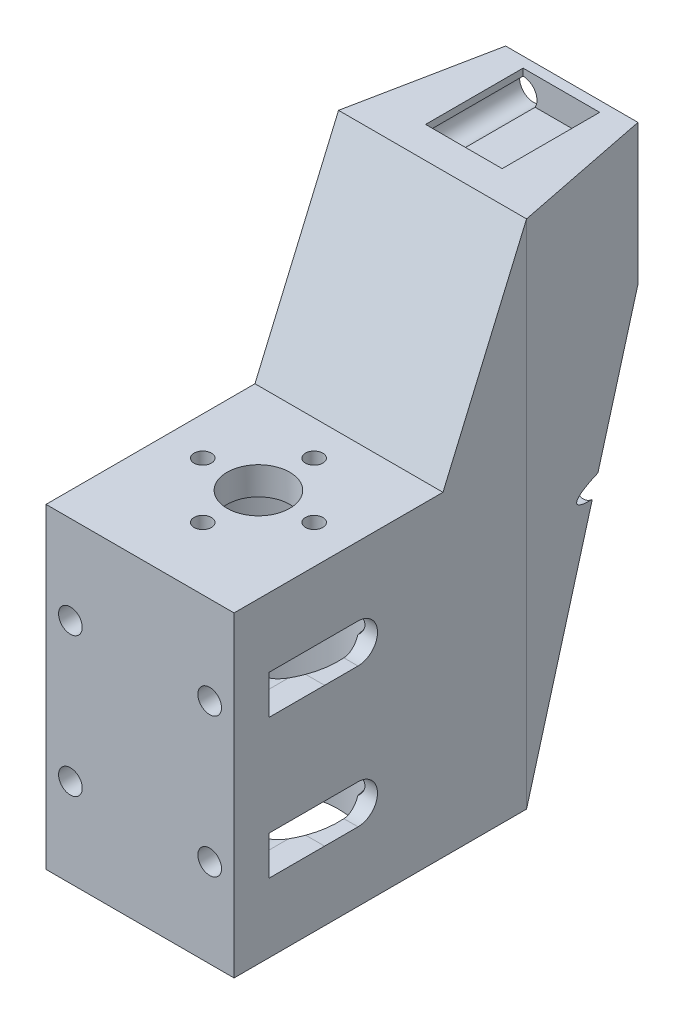
from build123d import *

# Parameters (mm, degrees)
SKETCH1_W                                       = 27
SKETCH1_H                                       = 62
BOSS_EXTRUDE1_DEPTH                             = 73.4
SKETCH2_R                                       = 2
CUT_EXTRUDE1_DEPTH                              = 20
SKETCH4_W                                       = 11
SKETCH4_H                                       = 14
CUT_EXTRUDE2_DEPTH                              = 4
SKETCH5_R                                       = 4.5
CUT_EXTRUDE3_DEPTH                              = 74.4
CUT_EXTRUDE4_START                              = -32
SKETCH6_R                                       = 11.5
CUT_EXTRUDE4_DEPTH                              = 42.4
CUT_EXTRUDE5_DEPTH                              = 28
M3_CLEARANCE_HOLE1_D                            = 3.4
CUT_EXTRUDE6_START                              = -5
CUT_EXTRUDE6_DEPTH                              = 8
CUT_EXTRUDE7_DEPTH                              = 74.4000001
TAP_DRILL_FOR_M3X0_5_TAP1_D                     = 2.5
CUT_EXTRUDE8_DEPTH                              = 28
CSK_FOR_M2_FLAT_HEAD_MACHINE_SCREW1_D           = 5.4
CSK_FOR_M2_FLAT_HEAD_MACHINE_SCREW1_DEPTH       = 6
CSK_FOR_M2_FLAT_HEAD_MACHINE_SCREW1_CSINK_D     = 5.6
CSK_FOR_M2_FLAT_HEAD_MACHINE_SCREW1_CSINK_ANGLE = 70
CSK_FOR_M2_FLAT_HEAD_MACHINE_SCREW1_TIP         = 1.622323671
CUT_EXTRUDE9_DEPTH                              = 28.0000001


with BuildPart() as part:
    # Sketch1 → Boss-Extrude1 (new body)
    with BuildSketch(Plane(origin=(0, 0, 0), x_dir=(1, 0, 0), z_dir=(0, 1, 0))):
        with Locations((0, 14)):
            Rectangle(SKETCH1_W, SKETCH1_H)
    extrude(amount=-BOSS_EXTRUDE1_DEPTH)

    # Sketch2 → Cut-Extrude1 (cut)
    with BuildSketch(Plane(origin=(0, 0, -45), x_dir=(-1, 0, 0), z_dir=(0, 0, -1))):
        with Locations((-5.5, -3)):
            Circle(SKETCH2_R)
        with Locations((5.5, -3)):
            Circle(SKETCH2_R)
    extrude(amount=-CUT_EXTRUDE1_DEPTH, mode=Mode.SUBTRACT)

    # Sketch4 → Cut-Extrude2 (cut)
    with BuildSketch(Plane(origin=(0, 0, 0), x_dir=(1, 0, 0), z_dir=(0, 1, 0))):
        with Locations((0, 36.5)):
            Rectangle(SKETCH4_W, SKETCH4_H)
    extrude(amount=-CUT_EXTRUDE2_DEPTH, mode=Mode.SUBTRACT)

    # Sketch5 → Cut-Extrude3 (cut, through all)
    with BuildSketch(Plane(origin=(0, 0, 0), x_dir=(1, 0, 0), z_dir=(0, 1, 0))):
        Circle(SKETCH5_R)
    extrude(amount=-CUT_EXTRUDE3_DEPTH, mode=Mode.SUBTRACT)

    # Sketch6 → Cut-Extrude4 (cut, through all)
    with BuildSketch(Plane(origin=(0, 0, 0), x_dir=(1, 0, 0), z_dir=(0, 1, 0)).offset(CUT_EXTRUDE4_START)):
        Circle(SKETCH6_R)
    extrude(amount=-CUT_EXTRUDE4_DEPTH, mode=Mode.SUBTRACT)

    # Sketch7 → Cut-Extrude5 (cut, through all)
    with BuildSketch(Plane(origin=(13.5, 0, 0), x_dir=(0, 0, -1), z_dir=(1, 0, 0))):
        Polygon((-17, -28), (13, -28), (25, 0), (-17, 0), align=None)
    extrude(amount=-CUT_EXTRUDE5_DEPTH, mode=Mode.SUBTRACT)

    # M3 Clearance Hole1 (through all)
    with Locations(Plane.XY.offset(17)):
        with Locations((-10, -60.7), (10, -60.7), (10, -40.7), (-10, -40.7)):
            Hole(M3_CLEARANCE_HOLE1_D / 2)

    # Sketch12 → Cut-Extrude6 (cut)
    with BuildSketch(Plane.XY.offset(17).offset(CUT_EXTRUDE6_START)):
        with BuildLine():
            Line((-10, -63.5), (-13.679961141, -63.5))
            Line((-13.679961141, -63.5), (-13.679961141, -57.9))
            Line((-13.679961141, -57.9), (-10, -57.9))
            ThreePointArc((-10, -57.9), (-7.2, -60.7), (-10, -63.5))
        make_face()
        with BuildLine():
            Line((-13.679961141, -43.5), (-13.679961141, -37.9))
            Line((-13.679961141, -37.9), (-10, -37.9))
            ThreePointArc((-10, -37.9), (-7.2, -40.7), (-10, -43.5))
            Line((-10, -43.5), (-13.679961141, -43.5))
        make_face()
        with BuildLine():
            Line((10, -43.5), (13.679961141, -43.5))
            Line((13.679961141, -43.5), (13.679961141, -37.9))
            Line((13.679961141, -37.9), (10, -37.9))
            ThreePointArc((10, -37.9), (7.2, -40.7), (10, -43.5))
        make_face()
        with BuildLine():
            Line((13.679961141, -57.9), (10, -57.9))
            ThreePointArc((10, -57.9), (7.2, -60.7), (10, -63.5))
            Line((10, -63.5), (13.679961141, -63.5))
            Line((13.679961141, -63.5), (13.679961141, -57.9))
        make_face()
    extrude(amount=-CUT_EXTRUDE6_DEPTH, mode=Mode.SUBTRACT)

    # Sketch13 → Cut-Extrude7 (cut, through all)
    with BuildSketch(Plane(origin=(0, 0, 0), x_dir=(1, 0, 0), z_dir=(0, 1, 0))):
        Polygon((-13.5, 25), (-9.5, 45), (-13.5, 45), align=None)
        Polygon((13.5, 45), (13.5, 25), (9.5, 45), align=None)
    extrude(amount=-CUT_EXTRUDE7_DEPTH, mode=Mode.SUBTRACT)

    # Tap Drill for M3x0.5 Tap1 (through all)
    with Locations(Plane(origin=(0, -28, 0), x_dir=(1, 0, 0), z_dir=(0, 1, 0))):
        with Locations((0, -8), (-8, 0), (0, 8), (8, 0), (0, 0)):
            Hole(TAP_DRILL_FOR_M3X0_5_TAP1_D / 2)

    # Sketch16 → Cut-Extrude8 (cut, through all)
    with BuildSketch(Plane(origin=(13.5, 0, 0), x_dir=(0, 0, -1), z_dir=(1, 0, 0))):
        with BuildLine():
            Line((-4, -37.900059373), (0.798420465, -37.900059373))
            ThreePointArc((0.798420465, -37.900059373), (3.598361092, -40.7), (0.798420465, -43.499940627))
            Line((0.798420465, -43.499940627), (-4, -43.499940627))
            ThreePointArc((-4, -43.499940627), (-6.799940627, -40.7), (-4, -37.900059373))
        make_face()
        with BuildLine():
            Line((-4, -57.900059373), (0.798420465, -57.900059373))
            ThreePointArc((0.798420465, -57.900059373), (3.598361092, -60.7), (0.798420465, -63.499940627))
            Line((0.798420465, -63.499940627), (-4, -63.499940627))
            ThreePointArc((-4, -63.499940627), (-6.799940627, -60.7), (-4, -57.900059373))
        make_face()
    extrude(amount=-CUT_EXTRUDE8_DEPTH, mode=Mode.SUBTRACT)

    # CSK for M2 Flat Head Machine Screw1
    with Locations(Plane(origin=(0, 0, -45), x_dir=(-1, 0, 0), z_dir=(0, 0, -1))):
        with Locations((0, -11)):
            CounterSinkHole(CSK_FOR_M2_FLAT_HEAD_MACHINE_SCREW1_D / 2, CSK_FOR_M2_FLAT_HEAD_MACHINE_SCREW1_CSINK_D / 2, depth=CSK_FOR_M2_FLAT_HEAD_MACHINE_SCREW1_DEPTH, counter_sink_angle=CSK_FOR_M2_FLAT_HEAD_MACHINE_SCREW1_CSINK_ANGLE)
            with Locations((0, 0, -(CSK_FOR_M2_FLAT_HEAD_MACHINE_SCREW1_DEPTH + CSK_FOR_M2_FLAT_HEAD_MACHINE_SCREW1_TIP / 2))):  # 118° drill point
                Cone(0, CSK_FOR_M2_FLAT_HEAD_MACHINE_SCREW1_D / 2, CSK_FOR_M2_FLAT_HEAD_MACHINE_SCREW1_TIP, mode=Mode.SUBTRACT)

    # Sketch20 → Cut-Extrude9 (cut, through all)
    with BuildSketch(Plane(origin=(13.5, 0, 0), x_dir=(0, 0, -1), z_dir=(1, 0, 0))):
        Polygon((25, -73.4), (47.12848035, -73.4), (47.12848035, -14.452819519), align=None)
    extrude(amount=-CUT_EXTRUDE9_DEPTH, mode=Mode.SUBTRACT)


solid = part.part
